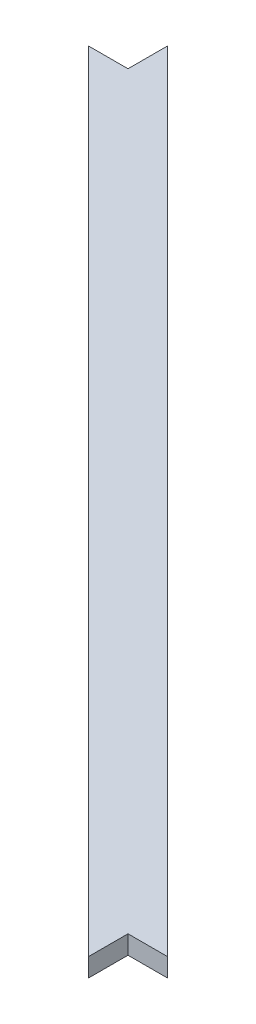
from build123d import *

# Parameters (mm, degrees)
BOSS_EXTRUDE1_DEPTH = 12.7


with BuildPart() as part:
    # Sketch1 → Boss-Extrude1 (new body)
    with BuildSketch(Plane(origin=(0, 0, 0), x_dir=(1, 0, 0), z_dir=(0, 1, 0))):
        Polygon((-256, 282.940768363), (-256, 256), (-282.940768363, 256), (256, -282.940768363), (256, -256), (282.940768363, -256), align=None)
    extrude(amount=BOSS_EXTRUDE1_DEPTH)


solid = part.part
